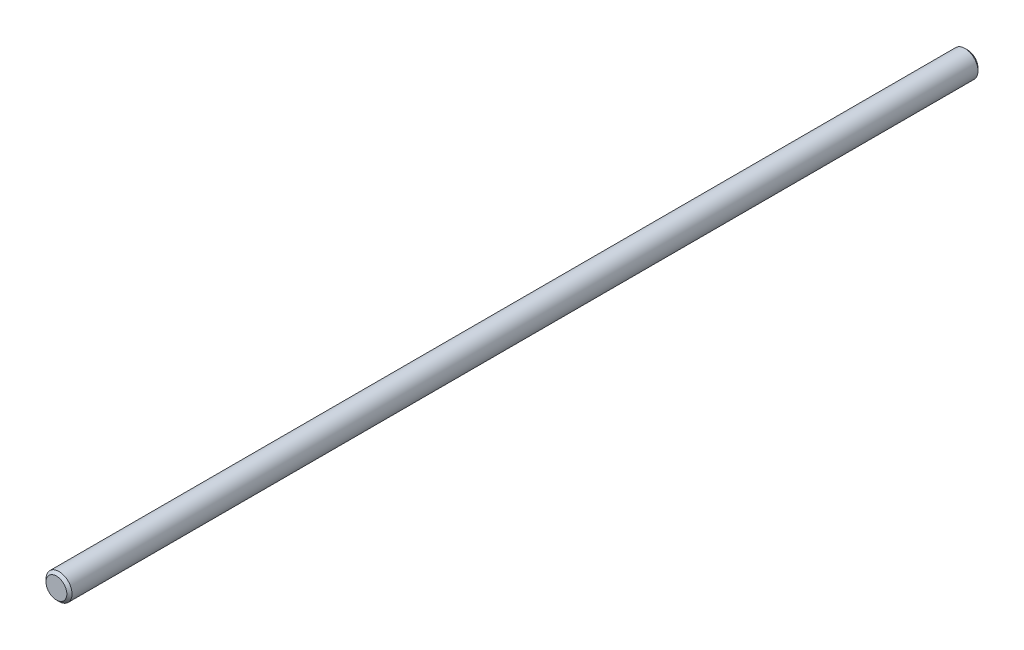
from build123d import *

# Parameters (mm, degrees)
SKETCH1_R      = 2.5
EXTRUDE1_DEPTH = 175
CHAMFER1_SIZE  = 0.5


with BuildPart() as part:
    # Sketch1 → Extrude1 (new body)
    with BuildSketch(Plane.XY):
        Circle(SKETCH1_R)
    extrude(amount=EXTRUDE1_DEPTH)

    # Chamfer1
    chamfer1_edges = [part.edges().sort_by_distance(p)[0] for p in [
        (-2.5, 0, 0),
        (-2.5, 0, 175),
    ]]
    chamfer(chamfer1_edges, length=CHAMFER1_SIZE)


solid = part.part
